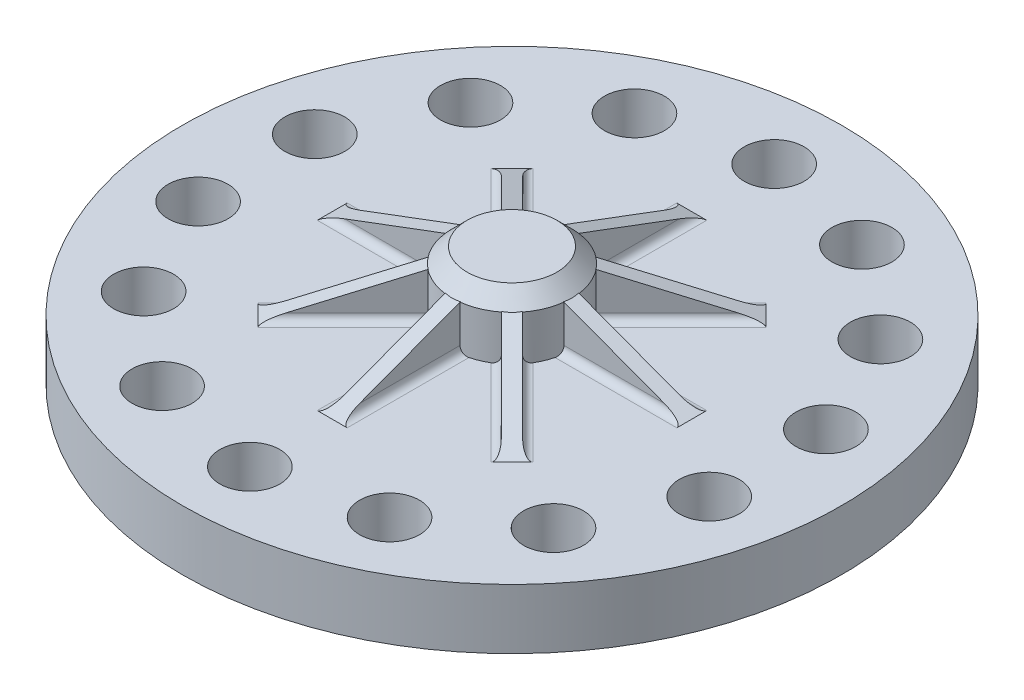
from build123d import *

# Parameters (mm, degrees)
SKETCH4_R                = 6.35
CUT_EXTRUDE1_DEPTH       = 100.595858348
RIB9_REACH               = 103.996
SKETCH6_WALL_W           = 233.119417624
SKETCH6_WALL_H           = 3.175
FILLET1_R                = 1.5875
CIRPATTERN1_COUNT        = 8
FILLET1_OF_CIRPATTERN1_R = 1.5875


with BuildPart() as part:
    # Sketch3 → Revolve1 (revolve)
    with BuildSketch(Plane.XY, mode=Mode.PRIVATE) as revolve1_sk:
        Polygon((0, 25.4), (9.525, 25.4), (12.7, 22.225), (12.7, 12.7), (69.85, 12.7), (69.85, 0), (0, 0), align=None)
    revolve(revolve1_sk.sketch.rotate(Axis((0, 0, 0), (0, 1, 0)), 90), axis=Axis((0, 0, 0), (0, 1, 0)))

    # Sketch4 → Cut-Extrude1 (cut, through all)
    with BuildSketch(Plane(origin=(0, 12.7, 0), x_dir=(1, 0, 0), z_dir=(0, 1, 0))):
        with Locations(Location((0, 55.5625, 0), (0, 0, 270))):
            Circle(SKETCH4_R)
        with Locations(Location((24.107665255, 50.060082723, 0), (0, 0, 270))):
            Circle(SKETCH4_R)
        with Locations(Location((43.440511745, 34.642652116, 0), (0, 0, 270))):
            Circle(SKETCH4_R)
        with Locations(Location((54.169432121, 12.363819393, 0), (0, 0, 270))):
            Circle(SKETCH4_R)
        with Locations(Location((54.169432121, -12.363819393, 0), (0, 0, 270))):
            Circle(SKETCH4_R)
        with Locations(Location((43.440511745, -34.642652116, 0), (0, 0, 270))):
            Circle(SKETCH4_R)
        with Locations(Location((24.107665255, -50.060082723, 0), (0, 0, 270))):
            Circle(SKETCH4_R)
        with Locations(Location((0, -55.5625, 0), (0, 0, 270))):
            Circle(SKETCH4_R)
        with Locations(Location((-24.107665255, -50.060082723, 0), (0, 0, 270))):
            Circle(SKETCH4_R)
        with Locations(Location((-43.440511745, -34.642652116, 0), (0, 0, 270))):
            Circle(SKETCH4_R)
        with Locations(Location((-54.169432121, -12.363819393, 0), (0, 0, 270))):
            Circle(SKETCH4_R)
        with Locations(Location((-54.169432121, 12.363819393, 0), (0, 0, 270))):
            Circle(SKETCH4_R)
        with Locations(Location((-43.440511745, 34.642652116, 0), (0, 0, 270))):
            Circle(SKETCH4_R)
        with Locations(Location((-24.107665255, 50.060082723, 0), (0, 0, 270))):
            Circle(SKETCH4_R)
    extrude(amount=-CUT_EXTRUDE1_DEPTH, mode=Mode.SUBTRACT)

    # Sketch6 wall → Rib9 (add, up to next)
    with BuildSketch(Plane(origin=(0, 17.4625, -25.4), x_dir=(0, -0.351123441588, -0.936329177569), z_dir=(0, 0.936329177569, -0.351123441588)), mode=Mode.PRIVATE) as rib9_sk1:
        Rectangle(SKETCH6_WALL_W, SKETCH6_WALL_H)
    rib9_tool1 = extrude(rib9_sk1.sketch, amount=-RIB9_REACH, mode=Mode.PRIVATE) - part.part
    rib9 = rib9_tool1.solids().sort_by_distance((0, 17.4625, -25.4))[0]
    add(rib9)

    # Fillet1
    fillet1_edges = [part.edges().sort_by_distance(p)[0] for p in [
        (1.5875, 12.7, -25.350195309),
        (-1.5875, 12.7, -25.350195309),
    ]]
    fillet(fillet1_edges, radius=FILLET1_R)

    # CirPattern1: Rib9 ×8 about axis
    cirpattern1_axis = Axis((0, 0, 0), (0, 1, 0))
    for i in range(1, CIRPATTERN1_COUNT):
        add(rib9.rotate(cirpattern1_axis, i * 360 / CIRPATTERN1_COUNT))

    # Fillet1 of CirPattern1
    fillet1_of_cirpattern1_edges = [part.edges().sort_by_distance(p)[0] for p in [
        (-16.802762993, 12.7, -19.047827023),
        (-19.047827023, 12.7, -16.802762993),
        (-25.350195309, 12.7, -1.5875),
        (-25.350195309, 12.7, 1.5875),
        (-19.047827023, 12.7, 16.802762993),
        (-16.802762993, 12.7, 19.047827023),
        (-1.5875, 12.7, 25.350195309),
        (1.5875, 12.7, 25.350195309),
        (16.802762993, 12.7, 19.047827023),
        (19.047827023, 12.7, 16.802762993),
        (25.350195309, 12.7, 1.5875),
        (25.350195309, 12.7, -1.5875),
        (19.047827023, 12.7, -16.802762993),
        (16.802762993, 12.7, -19.047827023),
    ]]
    fillet(fillet1_of_cirpattern1_edges, radius=FILLET1_OF_CIRPATTERN1_R)


solid = part.part
